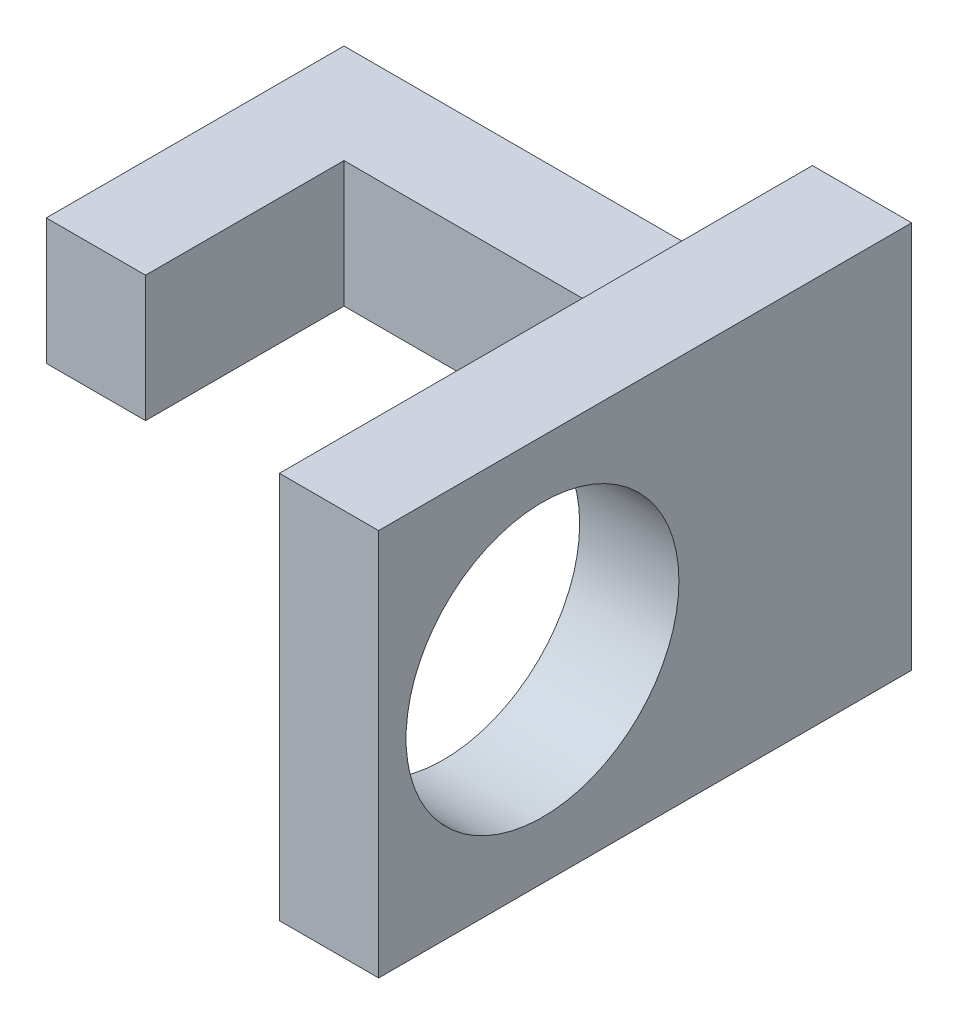
from build123d import *

# Parameters (mm, degrees)
BOSS_EXTRUDE1_DEPTH = 2.54
F_3DSKETCH1_R       = 2.75
BOSS_EXTRUDE3_DEPTH = 2


with BuildPart() as part:
    # Sketch1 → Boss-Extrude1 (new body)
    with BuildSketch(Plane(origin=(0, 0, 0), x_dir=(1, 0, 0), z_dir=(0, 1, 0))):
        Polygon((-24.263943822, 4.856129722), (-24.263943822, -1.143870278), (-22.263943822, -1.143870278), (-22.263943822, 2.856129722), (-14.821743822, 2.856129722), (-14.821743822, 4.856129722), align=None)
    extrude(amount=BOSS_EXTRUDE1_DEPTH)

    # 3DSketch1 → Boss-Extrude3 (add)
    with BuildSketch(Plane(origin=(-14.821743822, 5.174700089, 5.887638741), x_dir=(0, -0.5879624138152767, -0.808888249352476), z_dir=(1, 0, 0))):
        Polygon((0, 0), (4.591633779, -6.316932039), (13.282141842, 0), (8.690508063, 6.316932039), align=None)
        with Locations(Location((4.966765889, -1.217014129, 0), (0, 0, 36.012547839))):
            Circle(F_3DSKETCH1_R, mode=Mode.SUBTRACT)
    extrude(amount=BOSS_EXTRUDE3_DEPTH)


solid = part.part
